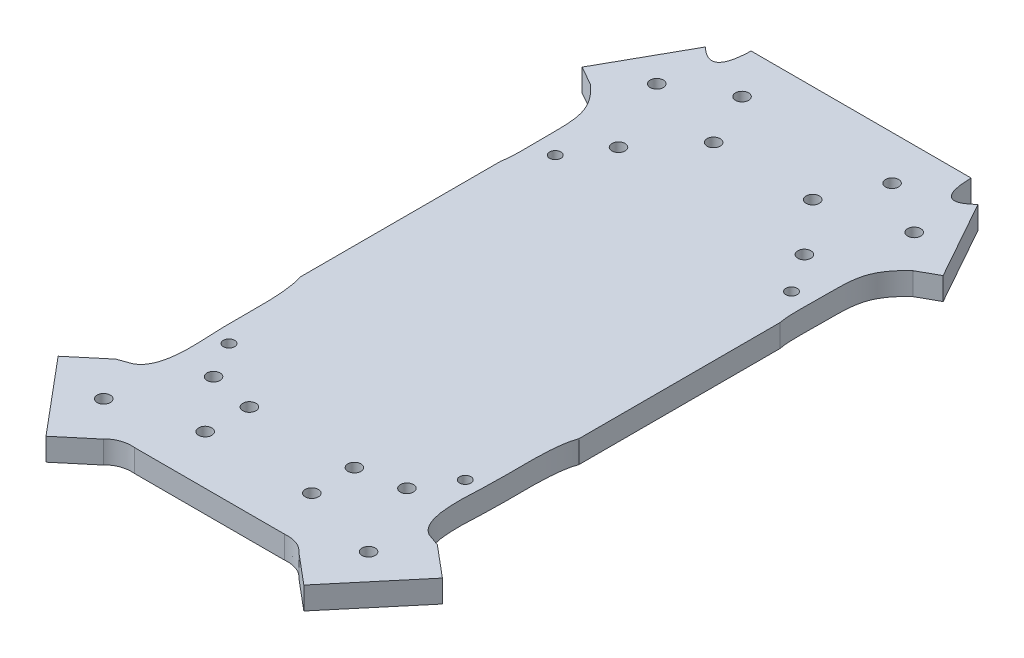
from build123d import *

# Parameters (mm, degrees)
SKETCH1_W               = 200
SKETCH1_H               = 250
BOSS_EXTRUDE1_DEPTH     = 6
F_3_0MM_DOWEL_HOLE1_D   = 3.5
SKETCH6_R               = 1.75
CUT_EXTRUDE3_DEPTH      = 2.2
SKETCH2_W               = 200
SKETCH2_H               = 253.519525226
CUT_EXTRUDE2_DEPTH      = 1
CUT_EXTRUDE2_DEPTH_BACK = 7
BOSS_EXTRUDE3_DEPTH     = 6
SKETCH13_R              = 1.5
CUT_EXTRUDE4_DEPTH      = 1.0000001
CUT_EXTRUDE4_DEPTH_BACK = 7.0000001


with BuildPart() as part:
    # Sketch1 → Boss-Extrude1 (new body)
    with BuildSketch(Plane(origin=(0, 0, 0), x_dir=(1, 0, 0), z_dir=(0, 1, 0))):
        with Locations((100, 125)):
            Rectangle(SKETCH1_W, SKETCH1_H)
    extrude(amount=BOSS_EXTRUDE1_DEPTH)

    # Ø3.0mm Dowel Hole1 (through all)
    with Locations(Plane(origin=(0, 0, 0), x_dir=(-1, 0, 0), z_dir=(0, -1, 0))):
        with Locations((-83.29683767, 150.137900155), (-94.867014644, 163.926700131), (-121.29683767, 163.926700131), (-132.867014644, 150.137900155), (-128.081926157, 178.292602477), (-142.402815019, 169.888052337), (-88.081926157, 178.292602477), (-73.761037294, 169.888052337), (-133.867014644, 43.137900155), (-122.081926157, 40.922048355), (-122.29683767, 29.349100179), (-94.081926157, 40.922048355), (-93.867014644, 29.349100179), (-82.29683767, 43.137900155), (-72.761037294, 23.387747973), (-143.402815019, 23.387747973)):
            Hole(F_3_0MM_DOWEL_HOLE1_D / 2)

    # Sketch6 → Cut-Extrude3 (cut)
    with BuildSketch(Plane.XZ):
        Polygon((125.09683767, -27.732519425), (122.29683767, -26.115938672), (119.49683767, -27.732519425), (119.49683767, -30.965680933), (122.29683767, -32.582261686), (125.09683767, -30.965680933), align=None)
        Polygon((133.867014644, -39.904738648), (131.067014644, -41.521319401), (131.067014644, -44.754480909), (133.867014644, -46.371061663), (136.667014644, -44.754480909), (136.667014644, -41.521319401), align=None)
        Polygon((82.29683767, -39.904738648), (79.49683767, -41.521319401), (79.49683767, -44.754480909), (82.29683767, -46.371061663), (85.09683767, -44.754480909), (85.09683767, -41.521319401), align=None)
        Polygon((93.867014644, -26.115938672), (91.067014644, -27.732519425), (91.067014644, -30.965680933), (93.867014644, -32.582261686), (96.667014644, -30.965680933), (96.667014644, -27.732519425), align=None)
        Polygon((94.867014644, -160.693538624), (92.067014644, -162.310119378), (92.067014644, -165.543280885), (94.867014644, -167.159861639), (97.667014644, -165.543280885), (97.667014644, -162.310119378), align=None)
        with Locations((94.867014644, -163.926700131)):
            Circle(SKETCH6_R, mode=Mode.SUBTRACT)
        Polygon((83.29683767, -146.904738648), (80.49683767, -148.521319401), (80.49683767, -151.754480909), (83.29683767, -153.371061663), (86.09683767, -151.754480909), (86.09683767, -148.521319401), align=None)
        with Locations((83.29683767, -150.137900155)):
            Circle(SKETCH6_R, mode=Mode.SUBTRACT)
        Polygon((121.29683767, -160.693538624), (118.49683767, -162.310119378), (118.49683767, -165.543280885), (121.29683767, -167.159861639), (124.09683767, -165.543280885), (124.09683767, -162.310119378), align=None)
        with Locations((121.29683767, -163.926700131)):
            Circle(SKETCH6_R, mode=Mode.SUBTRACT)
        Polygon((132.867014644, -153.371061663), (135.667014644, -151.754480909), (135.667014644, -148.521319401), (132.867014644, -146.904738648), (130.067014644, -148.521319401), (130.067014644, -151.754480909), align=None)
        with Locations((132.867014644, -150.137900155)):
            Circle(SKETCH6_R, mode=Mode.SUBTRACT)
    extrude(amount=-CUT_EXTRUDE3_DEPTH, mode=Mode.SUBTRACT)

    # Sketch2 → Cut-Extrude2 (cut, two sides)
    with BuildSketch(Plane.XZ) as cut_extrude2_sk:
        with Locations((100, -126.759762613)):
            Rectangle(SKETCH2_W, SKETCH2_H)
        with BuildLine():
            Line((143.206271193, -38.474324409), (139.348594785, -82.567767518))
            ThreePointArc((139.348594785, -82.567767518), (143.379983208, -88.766434624), (138.333453387, -94.170886794))
            Line((138.333453387, -94.170886794), (138.081926157, -97.045856194))
            Line((138.081926157, -97.045856194), (140.863131926, -149.832051752))
            ThreePointArc((140.863131926, -149.832051752), (142.359866063, -154.590769387), (145.969242496, -158.034315287))
            Line((145.969242496, -158.034315287), (156.230851695, -163.771558937))
            Line((156.230851695, -163.771558937), (144.440739957, -184.859301843))
            add(Edge.make_bspline(
                [(144.440739957, -184.859301843), (137.686448173, -178.410982542), (137.402815019, -190.036315102)],
                knots=[0, 0, 0, 1, 1, 1], degree=2))
            Line((137.402815019, -190.036315102), (78.761037294, -190.036315102))
            add(Edge.make_bspline(
                [(71.723112356, -184.859301843), (78.47740414, -178.410982542), (78.761037294, -190.036315102)],
                knots=[0, 0, 0, 1, 1, 1], degree=2))
            Line((71.723112356, -184.859301843), (59.933000618, -163.771558937))
            Line((59.933000618, -163.771558937), (70.194609818, -158.034315287))
            ThreePointArc((70.194609818, -158.034315287), (73.803986251, -154.590769387), (75.300720388, -149.832051752))
            Line((75.300720388, -149.832051752), (78.081926157, -97.045856194))
            Line((78.081926157, -97.045856194), (77.830398926, -94.170886794))
            ThreePointArc((77.830398926, -94.170886794), (72.783869106, -88.766434624), (76.815257528, -82.567767518))
            Line((76.815257528, -82.567767518), (72.95758112, -38.474324409))
            add(Edge.make_bspline(
                [(71.87426297, -36.548342356), (73.029938343, -36.460716162), (72.980934293, -37.754807476), (72.95758112, -38.474324409)],
                knots=[0, 0, 0, 0, 1, 1, 1, 1], degree=3))
            Line((71.87426297, -36.548342356), (65.214123879, -34.172936949))
            Line((65.214123879, -34.172936949), (56.844705507, -27.15016108))
            Line((56.844705507, -27.15016108), (73.702448882, -7.059884849))
            Line((73.702448882, -7.059884849), (82.071867254, -14.082660719))
            add(Edge.make_bspline(
                [(82.071867254, -14.082660719), (83.53149801, -15.797125086), (85.909052418, -16.455495951), (88.081926157, -16.243500167)],
                knots=[0, 0, 0, 0, 1, 1, 1, 1], degree=3))
            Line((88.081926157, -16.243500167), (128.081926157, -16.243500167))
            add(Edge.make_bspline(
                [(134.09198506, -14.082660719), (132.632354304, -15.797125086), (130.254799895, -16.455495951), (128.081926157, -16.243500167)],
                knots=[0, 0, 0, 0, 1, 1, 1, 1], degree=3))
            Line((134.09198506, -14.082660719), (142.461403432, -7.059884849))
            Line((142.461403432, -7.059884849), (159.319146807, -27.15016108))
            Line((159.319146807, -27.15016108), (150.949728435, -34.172936949))
            Line((150.949728435, -34.172936949), (144.289589344, -36.548342356))
            add(Edge.make_bspline(
                [(144.289589344, -36.548342356), (143.133913971, -36.460716162), (143.182918021, -37.754807476), (143.206271193, -38.474324409)],
                knots=[0, 0, 0, 0, 1, 1, 1, 1], degree=3))
        make_face(mode=Mode.SUBTRACT)
    extrude(amount=CUT_EXTRUDE2_DEPTH, mode=Mode.SUBTRACT)
    extrude(cut_extrude2_sk.sketch, amount=-CUT_EXTRUDE2_DEPTH_BACK, mode=Mode.SUBTRACT)

    # Sketch12 → Boss-Extrude3 (add)
    with BuildSketch(Plane.XZ):
        with BuildLine():
            Line((145.333785649, -131.181364351), (145.333785649, -77.629044584))
            add(Edge.make_bspline(
                [(147.619658889, -35.360639653), (142.777206683, -37.926752291), (144.388952605, -55.69848949), (143.790680066, -63.416837485), (144.241351516, -74.545098791), (145.333785649, -77.629044584)],
                knots=[0, 0, 0, 0, 0.389986275, 0.710398556, 0.928445879, 0.928445879, 0.928445879, 0.928445879], degree=3))
            Line((147.619658889, -35.360639653), (144.289589344, -36.548342356))
            add(Edge.make_bspline(
                [(143.206271193, -38.474324409), (143.182918021, -37.754807476), (143.133913971, -36.460716162), (144.289589344, -36.548342356)],
                knots=[0, 0, 0, 0, 1, 1, 1, 1], degree=3))
            Line((143.206271193, -38.474324409), (139.348594785, -82.567767518))
            ThreePointArc((139.348594785, -82.567767518), (143.379983208, -88.766434624), (138.333453387, -94.170886794))
            Line((138.333453387, -94.170886794), (138.081926157, -97.045856194))
            Line((138.081926157, -97.045856194), (140.863131926, -149.832051752))
            ThreePointArc((140.863131926, -149.832051752), (142.359866063, -154.590769387), (145.969242496, -158.034315287))
            Line((145.969242496, -158.034315287), (151.100047096, -160.902937112))
            add(Edge.make_bspline(
                [(151.100047096, -160.902937112), (144.231308287, -154.695867795), (145.4211977, -148.853665316), (144.801008685, -133.708262299), (145.333785649, -131.181364351)],
                knots=[0, 0, 0, 0, 0.606254863, 0.822010641, 0.822010641, 0.822010641, 0.822010641], degree=3))
        make_face()
        with BuildLine():
            Line((70.830066664, -131.181364351), (70.830066664, -77.629044584))
            add(Edge.make_bspline(
                [(68.544193424, -35.360639653), (73.38664563, -37.926752291), (71.774899708, -55.69848949), (72.373172248, -63.416837485), (71.922500798, -74.545098791), (70.830066664, -77.629044584)],
                knots=[0, 0, 0, 0, 0.389986275, 0.710398556, 0.928445879, 0.928445879, 0.928445879, 0.928445879], degree=3))
            Line((68.544193424, -35.360639653), (71.87426297, -36.548342356))
            add(Edge.make_bspline(
                [(72.95758112, -38.474324409), (72.980934293, -37.754807476), (73.029938343, -36.460716162), (71.87426297, -36.548342356)],
                knots=[0, 0, 0, 0, 1, 1, 1, 1], degree=3))
            Line((72.95758112, -38.474324409), (76.815257528, -82.567767518))
            ThreePointArc((76.815257528, -82.567767518), (72.783869106, -88.766434624), (77.830398926, -94.170886794))
            Line((77.830398926, -94.170886794), (78.081926157, -97.045856194))
            Line((78.081926157, -97.045856194), (75.300720388, -149.832051752))
            ThreePointArc((75.300720388, -149.832051752), (73.803986251, -154.590769387), (70.194609818, -158.034315287))
            Line((70.194609818, -158.034315287), (65.063805218, -160.902937112))
            add(Edge.make_bspline(
                [(65.063805218, -160.902937112), (71.932544027, -154.695867795), (70.742654614, -148.853665316), (71.362843629, -133.708262299), (70.830066664, -131.181364351)],
                knots=[0, 0, 0, 0, 0.606254863, 0.822010641, 0.822010641, 0.822010641, 0.822010641], degree=3))
        make_face()
    extrude(amount=-BOSS_EXTRUDE3_DEPTH)

    # Sketch13 → Cut-Extrude4 (cut, two sides)
    with BuildSketch(Plane.XZ) as cut_extrude4_sk:
        with Locations((139.6953643, -52.871061663)):
            Circle(SKETCH13_R)
        with Locations((76.6953643, -52.871061663)):
            Circle(SKETCH13_R)
        with Locations((76.6953643, -139.871061663)):
            Circle(SKETCH13_R)
        with Locations((139.6953643, -139.871061663)):
            Circle(SKETCH13_R)
    extrude(amount=CUT_EXTRUDE4_DEPTH, mode=Mode.SUBTRACT)
    extrude(cut_extrude4_sk.sketch, amount=-CUT_EXTRUDE4_DEPTH_BACK, mode=Mode.SUBTRACT)


solid = part.part
